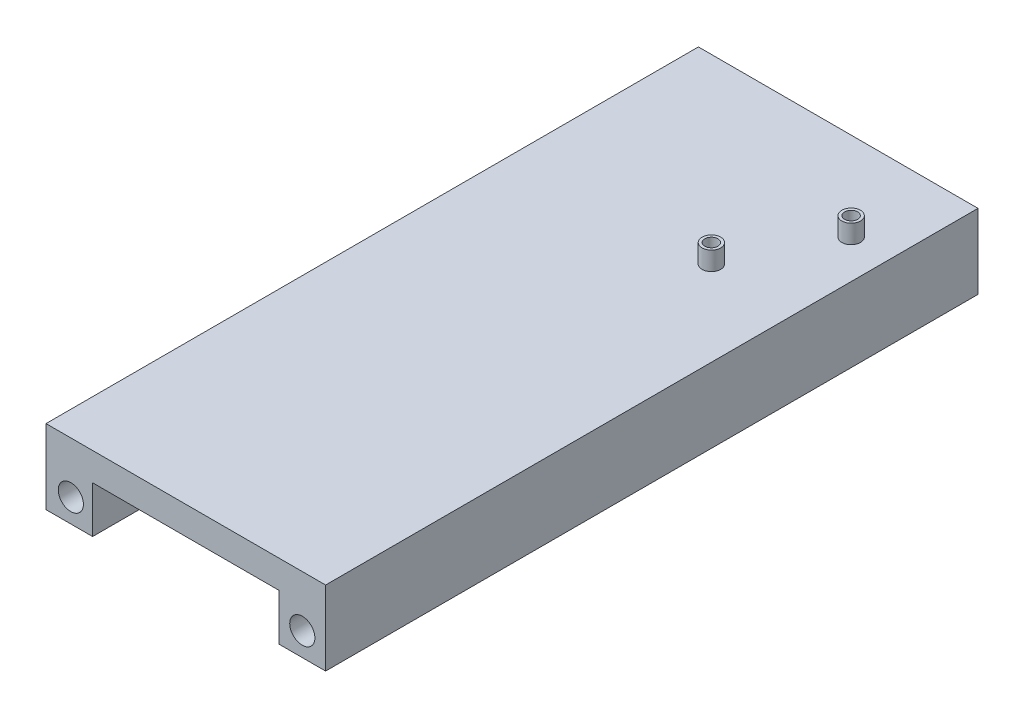
from build123d import *

# Parameters (mm, degrees)
SKETCH1_W           = 76.2
SKETCH1_H           = 177.8
BOSS_EXTRUDE1_DEPTH = 7.62
SKETCH4_W           = 12.7
SKETCH4_H           = 177.8
BOSS_EXTRUDE2_DEPTH = 12.7
SKETCH5_R           = 3.429
CUT_EXTRUDE1_DEPTH  = 178.8
SKETCH6_R           = 2.54
SKETCH6_R_2         = 1.778
BOSS_EXTRUDE3_DEPTH = 5.08


with BuildPart() as part:
    # Sketch1 → Boss-Extrude1 (new body)
    with BuildSketch(Plane(origin=(0, 0, 0), x_dir=(1, 0, 0), z_dir=(0, 1, 0))):
        with Locations((38.1, 88.9)):
            Rectangle(SKETCH1_W, SKETCH1_H)
    extrude(amount=BOSS_EXTRUDE1_DEPTH)

    # Sketch4 → Boss-Extrude2 (add)
    with BuildSketch(Plane.XZ):
        with Locations((6.35, -88.9)):
            Rectangle(SKETCH4_W, SKETCH4_H)
        with Locations((69.85, -88.9)):
            Rectangle(SKETCH4_W, SKETCH4_H)
    extrude(amount=BOSS_EXTRUDE2_DEPTH)

    # Sketch5 → Cut-Extrude1 (cut, through all)
    with BuildSketch(Plane(origin=(0, 0, -177.8), x_dir=(-1, 0, 0), z_dir=(0, 0, -1))):
        with Locations((-69.85, -6.35)):
            Circle(SKETCH5_R)
        with Locations((-6.772351806, -6.35)):
            Circle(SKETCH5_R)
    extrude(amount=-CUT_EXTRUDE1_DEPTH, mode=Mode.SUBTRACT)

    # Sketch6 → Boss-Extrude3 (add)
    with BuildSketch(Plane(origin=(0, 7.62, 0), x_dir=(1, 0, 0), z_dir=(0, 1, 0))):
        with Locations((53.0098, 128.3208)):
            Circle(SKETCH6_R)
        with Locations((53.0098, 128.3208)):
            Circle(SKETCH6_R_2, mode=Mode.SUBTRACT)
        with Locations((65.7098, 153.7208)):
            Circle(SKETCH6_R)
        with Locations((65.7098, 153.7208)):
            Circle(SKETCH6_R_2, mode=Mode.SUBTRACT)
    extrude(amount=BOSS_EXTRUDE3_DEPTH)


solid = part.part
